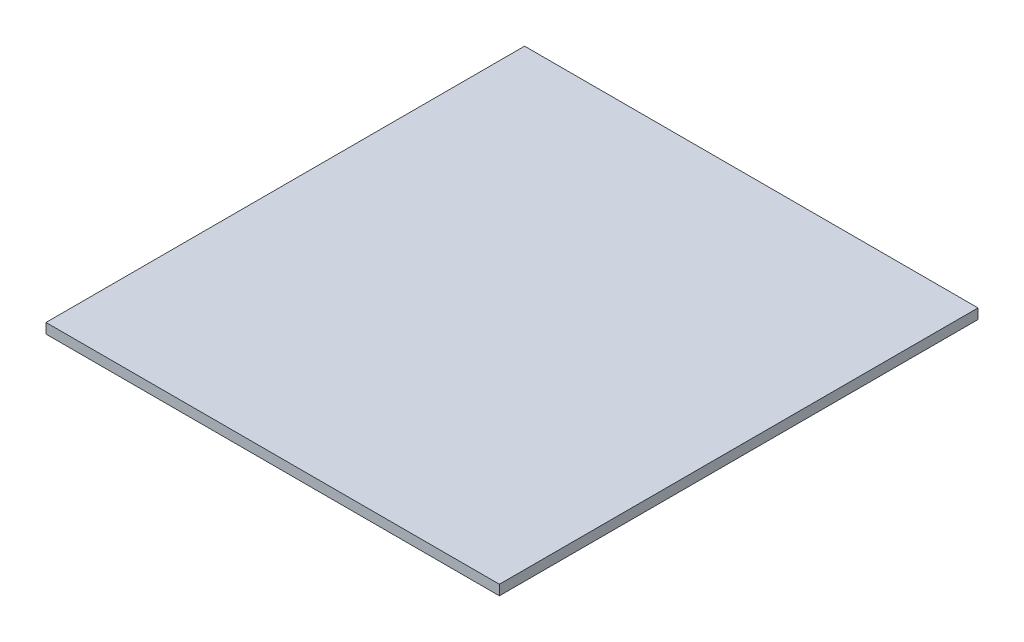
from build123d import *

# Parameters (mm, degrees)
ESBO_O1_W                = 180
ESBO_O1_H                = 4
RESSALTO_EXTRUS_O1_DEPTH = 190


with BuildPart() as part:
    # Esboço1 → Ressalto-extrusão1 (new body)
    with BuildSketch(Plane.XY):
        with Locations((90, 2)):
            Rectangle(ESBO_O1_W, ESBO_O1_H)
    extrude(amount=RESSALTO_EXTRUS_O1_DEPTH)


solid = part.part
